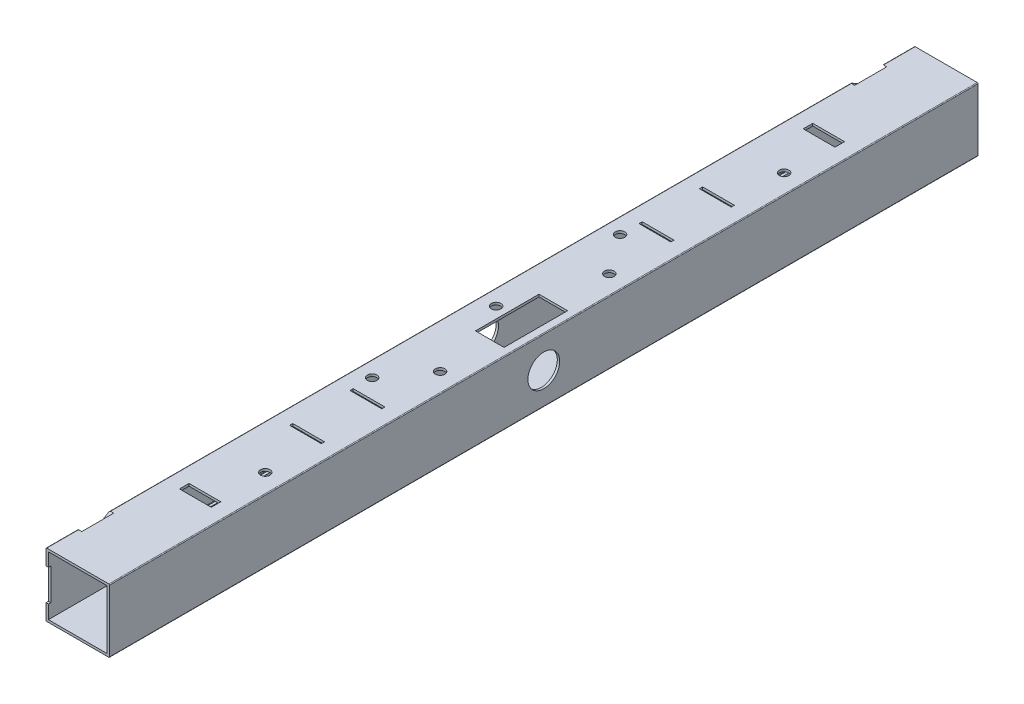
from build123d import *

# Parameters (mm, degrees)
SKETCH1_W           = 37
SKETCH1_H           = 37
BOSS_EXTRUDE1_DEPTH = 546.5
SKETCH2_W           = 1.5
SKETCH2_H           = 20
SKETCH2_W_2         = 80
SKETCH2_H_2         = 2
SKETCH2_W_3         = 2
SKETCH2_H_3         = 6
CUT_EXTRUDE1_DEPTH  = 2.5
SKETCH3_W           = 20
SKETCH3_H           = 6
CUT_EXTRUDE2_DEPTH  = 1.5
SKETCH4_W           = 20
SKETCH4_H           = 2
CUT_EXTRUDE3_DEPTH  = 2
SKETCH5_R           = 3
CUT_EXTRUDE4_DEPTH  = 550.419921372
SKETCH6_R           = 3
CUT_EXTRUDE5_DEPTH  = 550.419921372
SKETCH7_R           = 10
CUT_EXTRUDE6_DEPTH  = 550.419921372
SKETCH8_W           = 18
SKETCH8_H           = 40
CUT_EXTRUDE7_DEPTH  = 10


with BuildPart() as part:
    # Sketch1 → Boss-Extrude1 (new body)
    with BuildSketch(Plane.XY):
        with BuildLine():
            Line((0.5, 0), (39.5, 0))
            ThreePointArc((39.5, 0), (39.853553391, 0.146446609), (40, 0.5))
            Line((40, 0.5), (40, 39.5))
            ThreePointArc((40, 39.5), (39.853553391, 39.853553391), (39.5, 40))
            Line((39.5, 40), (0.5, 40))
            ThreePointArc((0.5, 40), (0.146446609, 39.853553391), (0, 39.5))
            Line((0, 39.5), (0, 0.5))
            ThreePointArc((0, 0.5), (0.146446609, 0.146446609), (0.5, 0))
        make_face()
        with Locations((20, 20)):
            Rectangle(SKETCH1_W, SKETCH1_H, mode=Mode.SUBTRACT)
    extrude(amount=BOSS_EXTRUDE1_DEPTH)

    # Sketch2 → Cut-Extrude1 (cut)
    with BuildSketch(Plane.ZY):
        with Locations((0.75, 20)):
            Rectangle(SKETCH2_W, SKETCH2_H)
        with Locations((39.25, 20)):
            Rectangle(SKETCH2_W, SKETCH2_H)
        with Locations((507.25, 20)):
            Rectangle(SKETCH2_W, SKETCH2_H)
        with Locations((545.75, 20)):
            Rectangle(SKETCH2_W, SKETCH2_H)
        with Locations((446.5, 13)):
            Rectangle(SKETCH2_W_2, SKETCH2_H_2)
        with Locations((100, 13)):
            Rectangle(SKETCH2_W_2, SKETCH2_H_2)
        with Locations((154, 9)):
            Rectangle(SKETCH2_W_3, SKETCH2_H_3)
        with Locations((392.5, 9)):
            Rectangle(SKETCH2_W_3, SKETCH2_H_3)
        Polygon((40.1, 40), (26.243593539, 32), (6.143593539, 32), (20, 40), align=None)
        Polygon((520.256406461, 32), (540.356406461, 32), (526.5, 40), (506.4, 40), align=None)
    extrude(amount=-CUT_EXTRUDE1_DEPTH, mode=Mode.SUBTRACT)

    # Sketch3 → Cut-Extrude2 (cut)
    with BuildSketch(Plane(origin=(0, 40, 0), x_dir=(1, 0, 0), z_dir=(0, 1, 0))):
        with Locations((20, -469.5)):
            Rectangle(SKETCH3_W, SKETCH3_H)
        with Locations((20, -77)):
            Rectangle(SKETCH3_W, SKETCH3_H)
    extrude(amount=-CUT_EXTRUDE2_DEPTH, mode=Mode.SUBTRACT)

    # Sketch4 → Cut-Extrude3 (cut)
    with BuildSketch(Plane(origin=(0, 40, 0), x_dir=(1, 0, 0), z_dir=(0, 1, 0))):
        with Locations((20, -144.3)):
            Rectangle(SKETCH4_W, SKETCH4_H)
        with Locations((20, -182.3)):
            Rectangle(SKETCH4_W, SKETCH4_H)
        with Locations((20, -364.2)):
            Rectangle(SKETCH4_W, SKETCH4_H)
        with Locations((20, -402.2)):
            Rectangle(SKETCH4_W, SKETCH4_H)
    extrude(amount=-CUT_EXTRUDE3_DEPTH, mode=Mode.SUBTRACT)

    # Sketch5 → Cut-Extrude4 (cut, through all)
    with BuildSketch(Plane.XZ):
        with Locations(Location((10, 351.25, 0), (0, 0, 270))):
            Circle(SKETCH5_R)
        with Locations(Location((10, 195.25, 0), (0, 0, 270))):
            Circle(SKETCH5_R)
        with Locations(Location((10, 273.25, 0), (0, 0, 270))):
            Circle(SKETCH5_R)
    extrude(amount=-CUT_EXTRUDE4_DEPTH, mode=Mode.SUBTRACT)

    # Sketch6 → Cut-Extrude5 (cut, through all)
    with BuildSketch(Plane(origin=(0, 0, 0), x_dir=(-1, 0, 0), z_dir=(0, -1, 0))):
        with Locations(Location((-28, -436.5, 0), (0, 0, 90))):
            Circle(SKETCH6_R)
        with Locations(Location((-28, -326.5, 0), (0, 0, 90))):
            Circle(SKETCH6_R)
        with Locations(Location((-28, -220, 0), (0, 0, 90))):
            Circle(SKETCH6_R)
        with Locations(Location((-28, -110, 0), (0, 0, 90))):
            Circle(SKETCH6_R)
    extrude(amount=-CUT_EXTRUDE5_DEPTH, mode=Mode.SUBTRACT)

    # Sketch7 → Cut-Extrude6 (cut, through all)
    with BuildSketch(Plane.ZY):
        with Locations((273.25, 20)):
            Circle(SKETCH7_R)
    extrude(amount=-CUT_EXTRUDE6_DEPTH, mode=Mode.SUBTRACT)

    # Sketch8 → Cut-Extrude7 (cut)
    with BuildSketch(Plane(origin=(0, 40, 0), x_dir=(1, 0, 0), z_dir=(0, 1, 0))):
        with Locations((26, -273.25)):
            Rectangle(SKETCH8_W, SKETCH8_H)
    extrude(amount=-CUT_EXTRUDE7_DEPTH, mode=Mode.SUBTRACT)


solid = part.part
